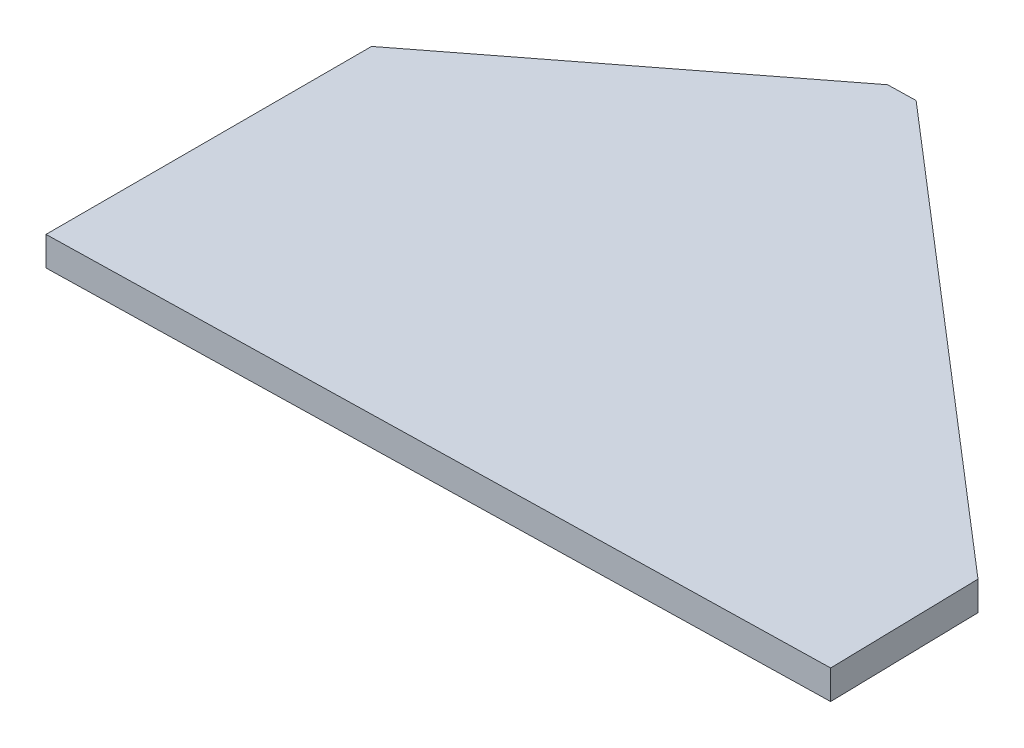
from build123d import *

# Parameters (mm, degrees)
BOSS_EXTRU_1_DEPTH = 2


with BuildPart() as part:
    # Esquisse1 → Boss.-Extru.1 (new body)
    with BuildSketch(Plane(origin=(0, 0, 0), x_dir=(1, 0, 0), z_dir=(0, 1, 0))):
        Polygon((0, 22.355321667), (0, 0), (52.726270899, 1.156021126), (52.499482218, 11.499881741), (21.914858616, 37.835803959), (19.995194696, 37.793715414), align=None)
    extrude(amount=BOSS_EXTRU_1_DEPTH)


solid = part.part
